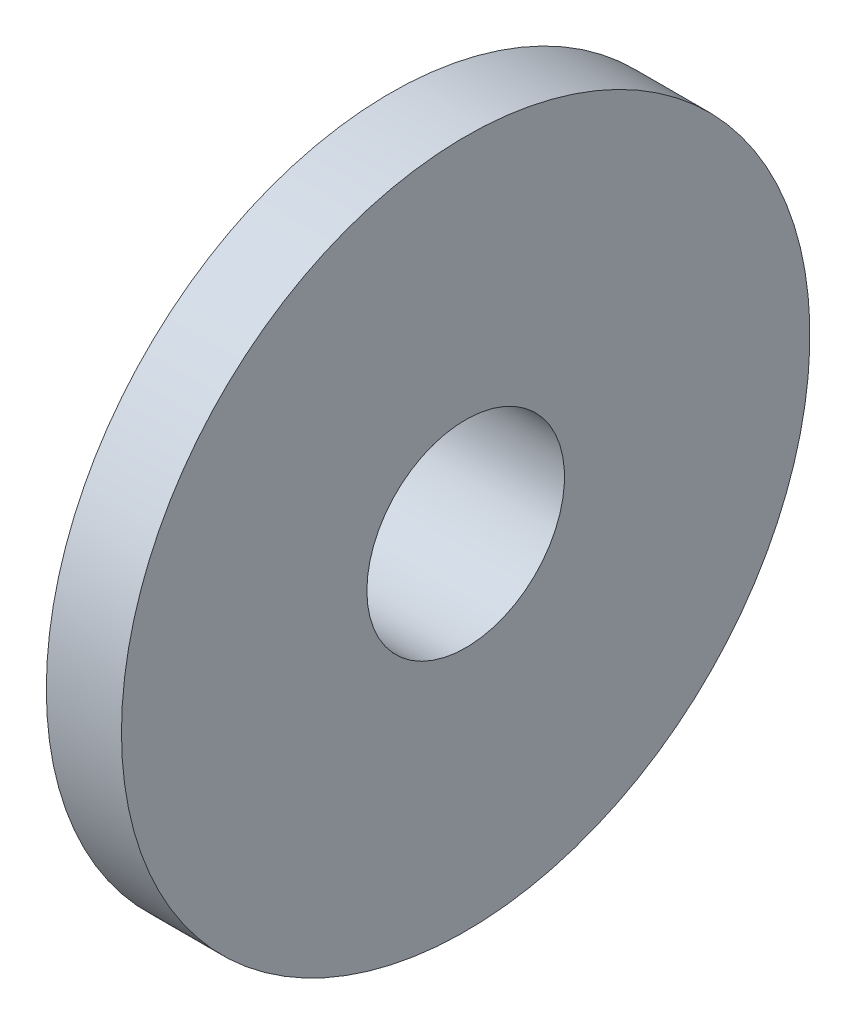
from build123d import *


with BuildPart() as part:
    # Sketch1 → Revolve1 (revolve)
    with BuildSketch(Plane(origin=(0, 0, 0), x_dir=(1, 0, 0), z_dir=(0, 1, 0))):
        Polygon((-8.735056791, 16.233067967), (-8.735056791, 8.747906619), (0, 8.747906619), (0, 23.006905401), (-4.367528396, 23.006905401), (-4.367528396, 16.233067967), align=None)
    revolve(axis=Axis((-12.067506203, 0, -3.006905401), (1, 0, 0)))


solid = part.part
